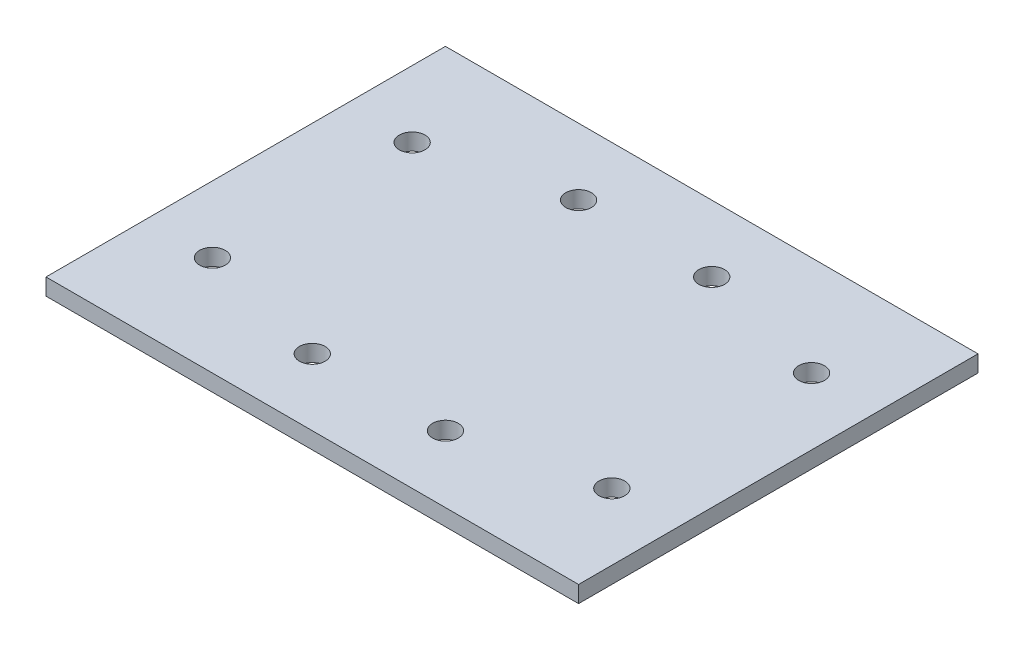
from build123d import *

# Parameters (mm, degrees)
SKETCH1_W               = 203.2
SKETCH1_H               = 152.4
BOSS_EXTRUDE1_DEPTH     = 6.35
F_3_8_CLEARANCE_HOLE1_D = 9.8044


with BuildPart() as part:
    # Sketch1 → Boss-Extrude1 (new body)
    with BuildSketch(Plane(origin=(0, 0, 0), x_dir=(1, 0, 0), z_dir=(0, 1, 0))):
        Rectangle(SKETCH1_W, SKETCH1_H)
    extrude(amount=BOSS_EXTRUDE1_DEPTH)

    # 3/8 Clearance Hole1 (through all)
    with Locations(Plane(origin=(0, 6.35, 0), x_dir=(1, 0, 0), z_dir=(0, 1, 0))):
        with Locations((-76.2, 38.1), (76.2, 38.1), (76.2, -38.1), (-76.2, -38.1), (-25.4, 50.8), (25.4, 50.8), (-25.4, -50.8), (25.4, -50.8)):
            Hole(F_3_8_CLEARANCE_HOLE1_D / 2)


solid = part.part
